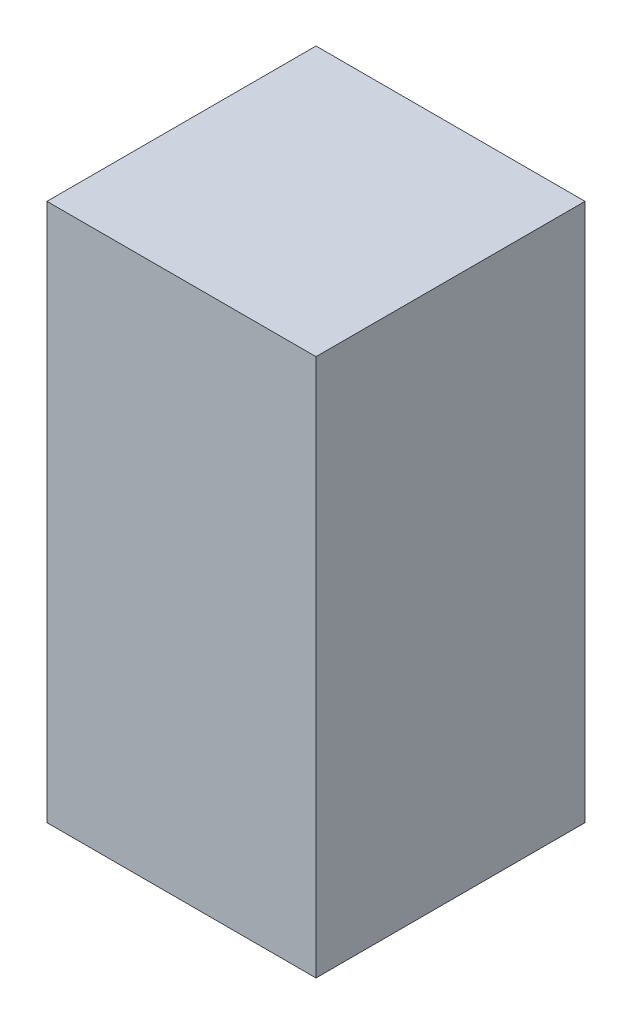
from build123d import *

# Parameters (mm, degrees)
SKETCH1_W           = 15
SKETCH1_H           = 30
BOSS_EXTRUDE1_DEPTH = 15


with BuildPart() as part:
    # Sketch1 → Boss-Extrude1 (new body)
    with BuildSketch(Plane.XY):
        Rectangle(SKETCH1_W, SKETCH1_H)
    extrude(amount=BOSS_EXTRUDE1_DEPTH)


solid = part.part
